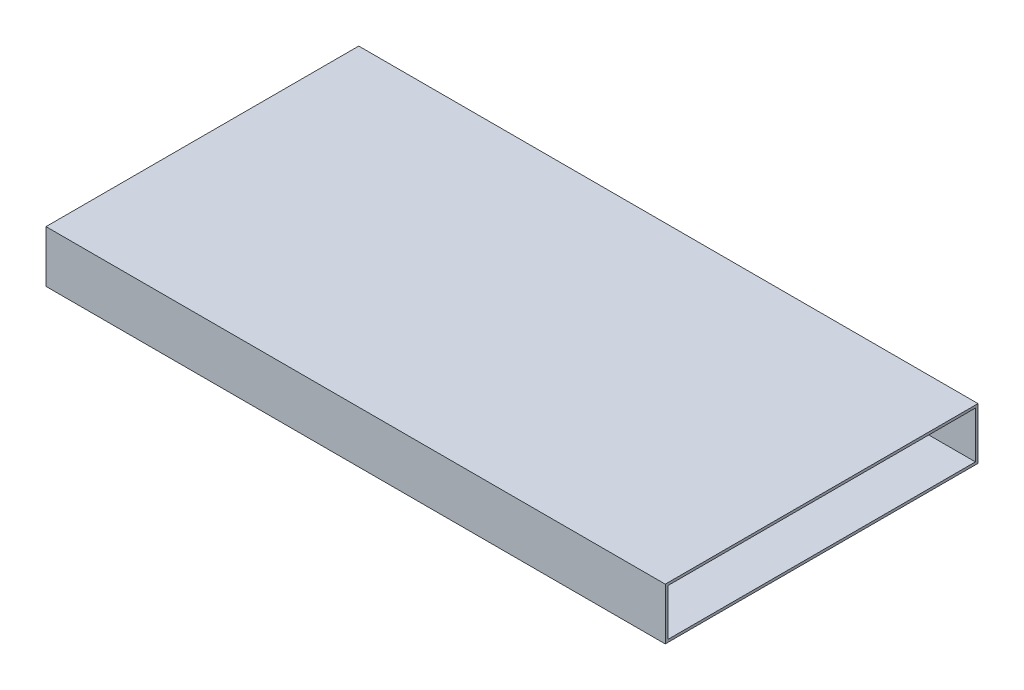
from build123d import *

# Parameters (mm, degrees)
CROQUIS1_W              = 119.537249877
CROQUIS1_H              = 60.370322505
SALIENTE_EXTRUIR1_DEPTH = 10
VACIADO1_T              = -0.5


with BuildPart() as part:
    # Croquis1 → Saliente-Extruir1 (new body)
    with BuildSketch(Plane(origin=(0, 0, 0), x_dir=(1, 0, 0), z_dir=(0, 1, 0))):
        with Locations((-59.768624939, -30.185161253)):
            Rectangle(CROQUIS1_W, CROQUIS1_H)
    extrude(amount=SALIENTE_EXTRUIR1_DEPTH)

    # Vaciado1
    vaciado1_openings = [part.faces().sort_by_distance(p)[0] for p in [
        (0, 5, 30.185161252),
    ]]
    offset(amount=VACIADO1_T, openings=vaciado1_openings, kind=Kind.INTERSECTION)


solid = part.part
